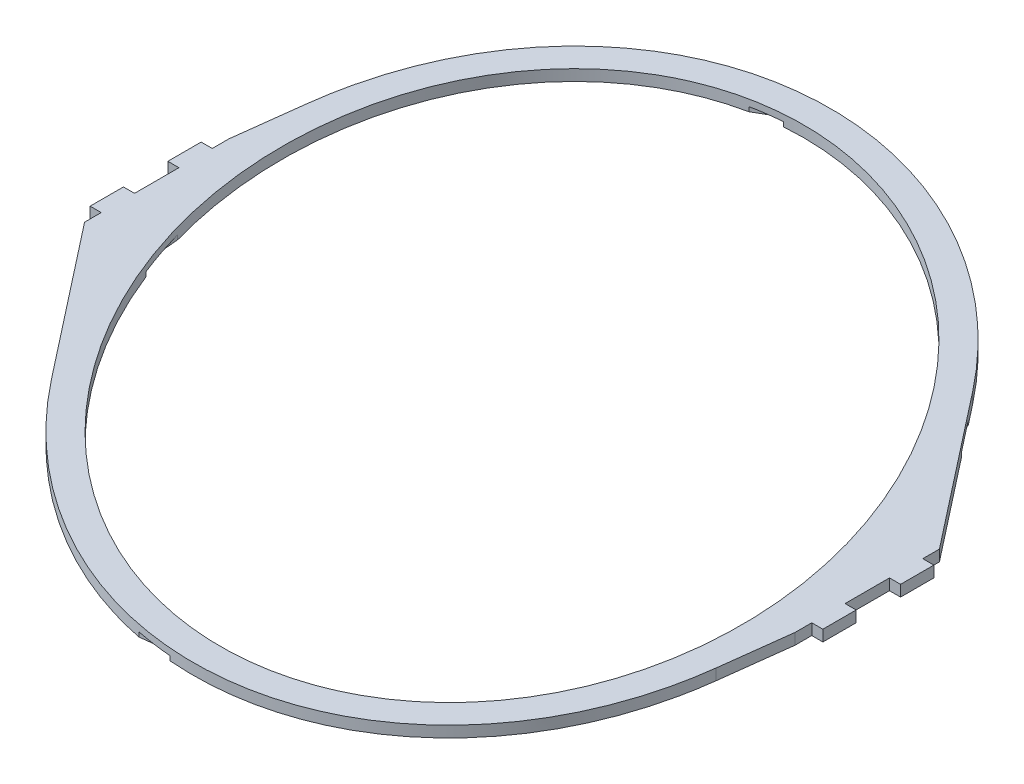
from build123d import *

# Parameters (mm, degrees)
SKETCH1_RX          = 355
SKETCH1_RY          = 265
BOSS_EXTRUDE1_DEPTH = 10
SKETCH2_RX          = 365
SKETCH2_RY          = 275
SKETCH2_RX_2        = 355
SKETCH2_RY_2        = 265
CUT_EXTRUDE1_DEPTH  = 4
CUT_EXTRUDE5_DEPTH  = 10


with BuildPart() as part:
    # Sketch1 → Boss-Extrude1 (new body)
    with BuildSketch(Plane(origin=(0, 0, 0), x_dir=(1, 0, 0), z_dir=(0, 1, 0))):
        with BuildLine():
            Line((-320, 50), (-320, 65))
            Line((-320, 65), (-312.170159719, 128.33520269))
            add(Edge.make_bspline(
                [(212.28214963, 202.588475219), (-232.721291269, 770.993291043), (-312.170159719, 128.33520269)],
                knots=[4.895798945, 4.895798945, 4.895798945, 7.074054013, 7.074054013, 7.074054013], degree=2, weights=[1, 0.463258742, 1]))
            Line((212.28214963, 202.588475219), (320, 65))
            Line((320, 65), (320, 50))
            Line((320, 50), (330, 50))
            Line((330, 50), (330, 20))
            Line((330, 20), (320, 20))
            Line((320, 20), (320, 0))
            Line((320, 0), (320, -20))
            Line((320, -20), (330, -20))
            Line((330, -20), (330, -50))
            Line((330, -50), (320, -50))
            Line((320, -50), (320, -65))
            Line((320, -65), (312.170159719, -128.33520269))
            add(Edge.make_bspline(
                [(-212.28214963, -202.588475219), (232.721291269, -770.993291043), (312.170159719, -128.33520269)],
                knots=[1.754206291, 1.754206291, 1.754206291, 3.932461359, 3.932461359, 3.932461359], degree=2, weights=[1, 0.463258742, 1]))
            Line((-212.28214963, -202.588475219), (-320, -65))
            Line((-320, -65), (-320, -50))
            Line((-320, -50), (-330, -50))
            Line((-330, -50), (-330, -20))
            Line((-330, -20), (-320, -20))
            Line((-320, -20), (-320, 0))
            Line((-320, 0), (-320, 20))
            Line((-320, 20), (-330, 20))
            Line((-330, 20), (-330, 50))
            Line((-330, 50), (-320, 50))
        make_face()
        with Locations(Location((0, 0), (0, 0, 120))):
            Ellipse(SKETCH1_RX, SKETCH1_RY, mode=Mode.SUBTRACT)
    extrude(amount=BOSS_EXTRUDE1_DEPTH)

    # Sketch2 → Cut-Extrude1 (cut)
    with BuildSketch(Plane.XZ):
        with Locations(Location((0, 0), (0, 0, 90))):
            Ellipse(SKETCH2_RX, SKETCH2_RY)
        with Locations(Location((0, 0), (0, 0, 90))):
            Ellipse(SKETCH2_RX_2, SKETCH2_RY_2, mode=Mode.SUBTRACT)
    extrude(amount=-CUT_EXTRUDE1_DEPTH, mode=Mode.SUBTRACT)

    # Sketch5 → Cut-Extrude5 (cut)
    with BuildSketch(Plane(origin=(290, 0, 0), x_dir=(0, 0, -1), z_dir=(1, 0, 0))):
        with BuildLine():
            Line((-2.5, 0), (2.5, 0))
            ThreePointArc((2.5, 0), (0, 2.5), (-2.5, 0))
        make_face()
    extrude(amount=-CUT_EXTRUDE5_DEPTH, mode=Mode.SUBTRACT)


solid = part.part
